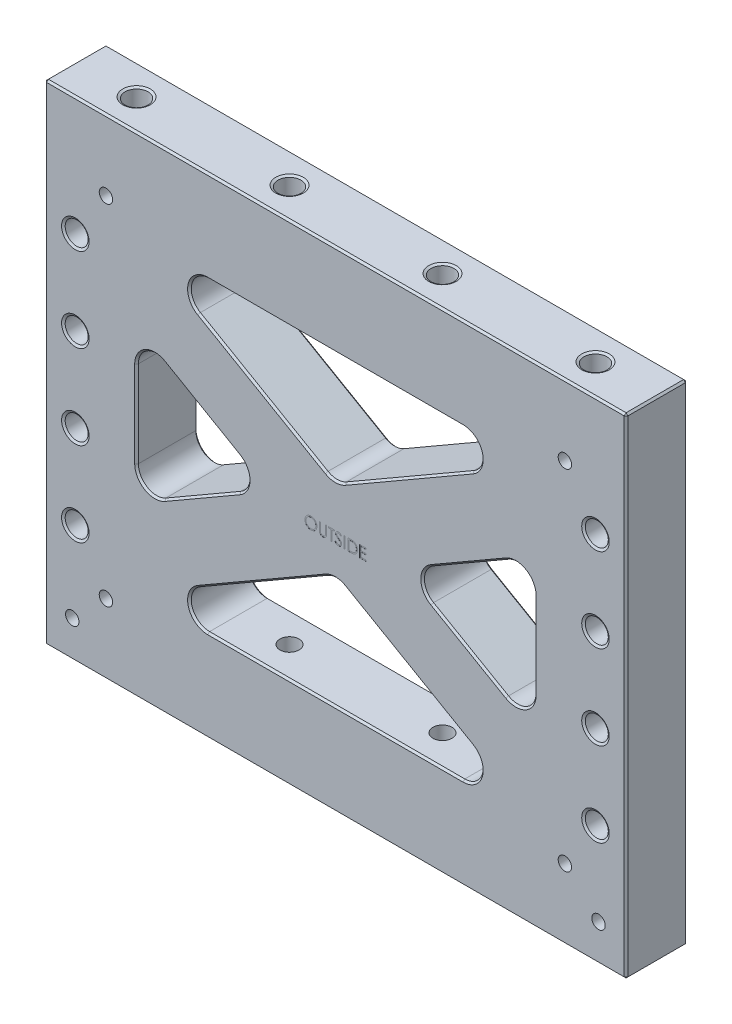
from build123d import *

# Parameters (mm, degrees)
SKETCH1_W                              = 241.3
SKETCH1_H                              = 203.2
EXTRUDE1_DEPTH                         = 25.4
SKETCH2_W                              = 165.1
SKETCH2_H                              = 127
EXTRUDE2_DEPTH                         = 26.4
EXTRUDE3_DEPTH                         = 25.4
FILLET1_R                              = 7.62
CHAMFER1_SIZE                          = 0.762
CHAMFER2_SIZE                          = 0.762
F_3_8_16_TAPPED_HOLE1_AT_2_COUNT       = 2
F_3_8_16_TAPPED_HOLE1_AT_2_PITCH       = 63.5
F_3_8_16_TAPPED_HOLE2_AT_2_COUNT       = 2
F_3_8_16_TAPPED_HOLE2_AT_2_PITCH       = 63.5
F_3_8_16_TAPPED_HOLE3_AT_2_COUNT       = 2
F_3_8_16_TAPPED_HOLE3_AT_2_PITCH       = 190.5
F_3_8_16_TAPPED_HOLE4_AT_2_COUNT       = 2
F_3_8_16_TAPPED_HOLE4_AT_2_PITCH       = 190.5
F_7_32_0_21875_VENT_HOLE1_D            = 5.55625
F_3_8_16_TAPPED_HOLE5_AT_2_COUNT       = 2
F_3_8_16_TAPPED_HOLE5_AT_2_PITCH       = 34.925
F_3_8_16_TAPPED_HOLE5_AT_3_COUNT       = 2
F_3_8_16_TAPPED_HOLE5_AT_3_PITCH       = 69.85
F_3_8_16_TAPPED_HOLE5_AT_4_COUNT       = 2
F_3_8_16_TAPPED_HOLE5_AT_4_PITCH       = 104.775
F_3_8_16_TAPPED_HOLE5_AT_5_COUNT       = 2
F_3_8_16_TAPPED_HOLE5_AT_5_PITCH       = 215.9
F_3_8_16_TAPPED_HOLE5_AT_6_COUNT       = 2
F_3_8_16_TAPPED_HOLE5_AT_6_PITCH       = 218.706574261
F_3_8_16_TAPPED_HOLE5_AT_7_COUNT       = 2
F_3_8_16_TAPPED_HOLE5_AT_7_PITCH       = 226.918118492
F_3_8_16_TAPPED_HOLE5_AT_8_COUNT       = 2
F_3_8_16_TAPPED_HOLE5_AT_8_PITCH       = 239.980438005
F_3_8_0_375_DIAMETER_HOLE2_D           = 9.54278
F_3_8_0_375_DIAMETER_HOLE2_DEPTH       = 19.05
F_3_8_0_375_DIAMETER_HOLE2_CSINK_D     = 14.224
F_3_8_0_375_DIAMETER_HOLE2_CSINK_ANGLE = 90
F_3_8_0_375_DIAMETER_HOLE2_TIP         = 2.866940349
EXTRUDE14_DEPTH                        = 19.05
CHAMFER4_SIZE                          = 2.286
F_7_32_0_21875_DIAMETER_HOLE3_D        = 5.55625
SKETCH36_W                             = 0.427403846
SKETCH36_H                             = 4.7625
EXTRUDE15_DEPTH                        = 0.0254


with BuildPart() as part:
    # Sketch1 → Extrude1 (new body)
    with BuildSketch(Plane.XY):
        with Locations((0, 101.6)):
            Rectangle(SKETCH1_W, SKETCH1_H)
    extrude(amount=EXTRUDE1_DEPTH)

    # Sketch2 → Extrude2 (cut, through all)
    with BuildSketch(Plane.XY.offset(25.4)):
        with Locations((0, 101.6)):
            Rectangle(SKETCH2_W, SKETCH2_H)
    extrude(amount=-EXTRUDE2_DEPTH, mode=Mode.SUBTRACT)

    # Sketch3 → Extrude3 (add)
    with BuildSketch(Plane.XY.offset(25.4)):
        Polygon((-82.55, 132.76248078), (-82.55, 165.1), (-81.410226281, 165.1), (82.55, 70.43751922), (82.55, 38.1), (81.410226281, 38.1), align=None)
    extrude3 = extrude(amount=-EXTRUDE3_DEPTH)

    # Mirror1: Extrude3 across plane
    add(extrude3.mirror(Plane(origin=(0, 0, 0), x_dir=(0, 0, 1), z_dir=(1, 0, 0))))

    # Fillet1
    fillet1_edges = [part.edges().sort_by_distance(p)[0] for p in [
        (82.55, 70.43751922, 12.7),
        (-81.410226281, 165.1, 12.7),
        (-82.55, 132.76248078, 12.7),
        (81.410226281, 38.1, 12.7),
        (-28.575, 101.6, 12.7),
        (0, 85.102216058, 12.7),
        (28.575, 101.6, 12.7),
        (82.55, 132.76248078, 12.7),
        (0, 118.097783942, 12.7),
        (-81.410226281, 38.1, 12.7),
        (-82.55, 70.43751922, 12.7),
        (81.410226281, 165.1, 12.7),
    ]]
    fillet(fillet1_edges, radius=FILLET1_R)

    # Chamfer1
    chamfer1_edges = [part.edges().sort_by_distance(p)[0] for p in [
        (82.55, 101.6, 0),
        (82.55, 101.6, 25.4),
        (55.5625, 86.01875961, 0),
        (55.5625, 86.01875961, 25.4),
        (55.5625, 117.18124039, 0),
        (55.5625, 117.18124039, 25.4),
        (-30.295999563, 135.589187445, 25.4),
        (-30.295999563, 135.589187445, 0),
        (-60.332353923, 43.747798876, 25.4),
        (-60.332353923, 43.747798876, 0),
        (60.332353923, 43.747798876, 25.4),
        (60.332353923, 43.747798876, 0),
        (0, 83.923397955, 0),
        (0, 83.923397955, 25.4),
        (60.332353923, 159.452201124, 25.4),
        (60.332353923, 159.452201124, 0),
        (-78.74, 126.163367203, 25.4),
        (-78.74, 126.163367203, 0),
        (-78.74, 77.036632797, 25.4),
        (-78.74, 77.036632797, 0),
        (-36.195, 101.6, 25.4),
        (-36.195, 101.6, 0),
        (78.74, 77.036632797, 25.4),
        (78.74, 77.036632797, 0),
        (78.74, 126.163367203, 25.4),
        (78.74, 126.163367203, 0),
        (36.195, 101.6, 25.4),
        (36.195, 101.6, 0),
        (0, 119.276602045, 0),
        (0, 119.276602045, 25.4),
        (-60.332353923, 159.452201124, 25.4),
        (-60.332353923, 159.452201124, 0),
        (0, 38.1, 25.4),
        (0, 38.1, 0),
        (-30.295999563, 67.610812555, 25.4),
        (-30.295999563, 67.610812555, 0),
        (30.295999563, 67.610812555, 25.4),
        (30.295999563, 67.610812555, 0),
        (0, 165.1, 25.4),
        (0, 165.1, 0),
        (30.295999563, 135.589187445, 25.4),
        (30.295999563, 135.589187445, 0),
        (-82.55, 101.6, 0),
        (-82.55, 101.6, 25.4),
        (-55.5625, 117.18124039, 0),
        (-55.5625, 117.18124039, 25.4),
        (-55.5625, 86.01875961, 0),
        (-55.5625, 86.01875961, 25.4),
    ]]
    chamfer(chamfer1_edges, length=CHAMFER1_SIZE)

    # Chamfer2
    chamfer2_edges = [part.edges().sort_by_distance(p)[0] for p in [
        (120.65, 101.6, 25.4),
        (0, 203.2, 25.4),
        (-120.65, 101.6, 25.4),
        (0, 203.2, 0),
        (120.65, 101.6, 0),
        (0, 0, 0),
        (-120.65, 101.6, 0),
        (0, 0, 25.4),
        (-120.65, 203.2, 12.7),
        (120.65, 203.2, 12.7),
        (120.65, 0, 12.7),
        (-120.65, 0, 12.7),
    ]]
    chamfer(chamfer2_edges, length=CHAMFER2_SIZE)

    # Sketch6 → 3/8-16 Tapped Hole1 (revolve, cut)
    with BuildSketch(Plane(origin=(-31.75, 203.2, 12.7), x_dir=(0, 0, 1), z_dir=(1, 0, 0))):
        Polygon((0, 0), (0, 40.484665582), (3.96875, 38.1), (3.96875, 25.4), (4.7625, 25.4), (4.7625, 0.549926131), (5.715, 0), align=None)
    f_3_8_16_tapped_hole1 = revolve(axis=Axis((-31.75, 209.55, 12.7), (0, -1, 0)), mode=Mode.SUBTRACT)

    # 3/8-16 Tapped Hole1 at 2: 3/8-16 Tapped Hole1 ×2
    with Locations(*[(i * F_3_8_16_TAPPED_HOLE1_AT_2_PITCH, 0, 0) for i in range(1, F_3_8_16_TAPPED_HOLE1_AT_2_COUNT)]):
        add(f_3_8_16_tapped_hole1, mode=Mode.SUBTRACT)

    # Sketch8 → 3/8-16 Tapped Hole2 (revolve, cut)
    with BuildSketch(Plane(origin=(-31.75, 0, 12.7), x_dir=(0, 0, -1), z_dir=(1, 0, 0))):
        Polygon((0, 0), (0, 40.484665582), (3.96875, 38.1), (3.96875, 25.4), (4.7625, 25.4), (4.7625, 0.549926131), (5.715, 0), align=None)
    f_3_8_16_tapped_hole2 = revolve(axis=Axis((-31.75, -6.35, 12.7), (0, 1, 0)), mode=Mode.SUBTRACT)

    # 3/8-16 Tapped Hole2 at 2: 3/8-16 Tapped Hole2 ×2
    with Locations(*[(i * F_3_8_16_TAPPED_HOLE2_AT_2_PITCH, 0, 0) for i in range(1, F_3_8_16_TAPPED_HOLE2_AT_2_COUNT)]):
        add(f_3_8_16_tapped_hole2, mode=Mode.SUBTRACT)

    # Sketch10 → 3/8-16 Tapped Hole3 (revolve, cut)
    with BuildSketch(Plane(origin=(-95.25, 203.2, 12.7), x_dir=(0, 0, 1), z_dir=(1, 0, 0))):
        Polygon((0, 0), (0, 40.484665582), (3.96875, 38.1), (3.96875, 25.4), (4.7625, 25.4), (4.7625, 0.549926131), (5.715, 0), align=None)
    f_3_8_16_tapped_hole3 = revolve(axis=Axis((-95.25, 209.55, 12.7), (0, -1, 0)), mode=Mode.SUBTRACT)

    # 3/8-16 Tapped Hole3 at 2: 3/8-16 Tapped Hole3 ×2
    with Locations(*[(i * F_3_8_16_TAPPED_HOLE3_AT_2_PITCH, 0, 0) for i in range(1, F_3_8_16_TAPPED_HOLE3_AT_2_COUNT)]):
        add(f_3_8_16_tapped_hole3, mode=Mode.SUBTRACT)

    # Sketch12 → 3/8-16 Tapped Hole4 (revolve, cut)
    with BuildSketch(Plane(origin=(-95.25, 0, 12.7), x_dir=(0, 0, -1), z_dir=(1, 0, 0))):
        Polygon((0, 0), (0, 40.484665582), (3.96875, 38.1), (3.96875, 25.4), (4.7625, 25.4), (4.7625, 0.549926131), (5.715, 0), align=None)
    f_3_8_16_tapped_hole4 = revolve(axis=Axis((-95.25, -6.35, 12.7), (0, 1, 0)), mode=Mode.SUBTRACT)

    # 3/8-16 Tapped Hole4 at 2: 3/8-16 Tapped Hole4 ×2
    with Locations(*[(i * F_3_8_16_TAPPED_HOLE4_AT_2_PITCH, 0, 0) for i in range(1, F_3_8_16_TAPPED_HOLE4_AT_2_COUNT)]):
        add(f_3_8_16_tapped_hole4, mode=Mode.SUBTRACT)

    # 7/32 (0.21875) Vent Hole1 (through all)
    with Locations(Plane.XY.offset(25.4)):
        with Locations((-95.25, 173.99), (95.25, 173.99), (-95.25, 29.21), (95.25, 29.21)):
            Hole(F_7_32_0_21875_VENT_HOLE1_D / 2)

    # Sketch14 → 3/8-16 Tapped Hole5 (revolve, cut)
    with BuildSketch(Plane(origin=(-107.95, 153.9875, 0), x_dir=(0, 1, 0), z_dir=(1, 0, 0))):
        Polygon((0, 0), (0, 25.4), (5.715, 25.4), (4.7625, 24.850073869), (4.7625, 0.549926131), (5.715, 0), align=None)
    f_3_8_16_tapped_hole5 = revolve(axis=Axis((-107.95, 153.9875, -6.35), (0, 0, 1)), mode=Mode.SUBTRACT)

    # 3/8-16 Tapped Hole5 at 2: 3/8-16 Tapped Hole5 ×2
    with Locations(*[(0, -i * F_3_8_16_TAPPED_HOLE5_AT_2_PITCH, 0) for i in range(1, F_3_8_16_TAPPED_HOLE5_AT_2_COUNT)]):
        add(f_3_8_16_tapped_hole5, mode=Mode.SUBTRACT)

    # 3/8-16 Tapped Hole5 at 3: 3/8-16 Tapped Hole5 ×2
    with Locations(*[(0, -i * F_3_8_16_TAPPED_HOLE5_AT_3_PITCH, 0) for i in range(1, F_3_8_16_TAPPED_HOLE5_AT_3_COUNT)]):
        add(f_3_8_16_tapped_hole5, mode=Mode.SUBTRACT)

    # 3/8-16 Tapped Hole5 at 4: 3/8-16 Tapped Hole5 ×2
    with Locations(*[(0, -i * F_3_8_16_TAPPED_HOLE5_AT_4_PITCH, 0) for i in range(1, F_3_8_16_TAPPED_HOLE5_AT_4_COUNT)]):
        add(f_3_8_16_tapped_hole5, mode=Mode.SUBTRACT)

    # 3/8-16 Tapped Hole5 at 5: 3/8-16 Tapped Hole5 ×2
    with Locations(*[(i * F_3_8_16_TAPPED_HOLE5_AT_5_PITCH, 0, 0) for i in range(1, F_3_8_16_TAPPED_HOLE5_AT_5_COUNT)]):
        add(f_3_8_16_tapped_hole5, mode=Mode.SUBTRACT)

    # 3/8-16 Tapped Hole5 at 6: 3/8-16 Tapped Hole5 ×2
    with Locations(*[Vector(0.987167399, -0.159688844, 0) * (i * F_3_8_16_TAPPED_HOLE5_AT_6_PITCH) for i in range(1, F_3_8_16_TAPPED_HOLE5_AT_6_COUNT)]):
        add(f_3_8_16_tapped_hole5, mode=Mode.SUBTRACT)

    # 3/8-16 Tapped Hole5 at 7: 3/8-16 Tapped Hole5 ×2
    with Locations(*[Vector(0.951444519, -0.307820285, 0) * (i * F_3_8_16_TAPPED_HOLE5_AT_7_PITCH) for i in range(1, F_3_8_16_TAPPED_HOLE5_AT_7_COUNT)]):
        add(f_3_8_16_tapped_hole5, mode=Mode.SUBTRACT)

    # 3/8-16 Tapped Hole5 at 8: 3/8-16 Tapped Hole5 ×2
    with Locations(*[Vector(0.899656663, -0.436598086, 0) * (i * F_3_8_16_TAPPED_HOLE5_AT_8_PITCH) for i in range(1, F_3_8_16_TAPPED_HOLE5_AT_8_COUNT)]):
        add(f_3_8_16_tapped_hole5, mode=Mode.SUBTRACT)

    # 3/8 (0.375) Diameter Hole2
    with Locations(Plane.XZ):
        with Locations((-109.22, 12.7)):
            CounterSinkHole(F_3_8_0_375_DIAMETER_HOLE2_D / 2, F_3_8_0_375_DIAMETER_HOLE2_CSINK_D / 2, depth=F_3_8_0_375_DIAMETER_HOLE2_DEPTH, counter_sink_angle=F_3_8_0_375_DIAMETER_HOLE2_CSINK_ANGLE)
            with Locations((0, 0, -(F_3_8_0_375_DIAMETER_HOLE2_DEPTH + F_3_8_0_375_DIAMETER_HOLE2_TIP / 2))):  # 118° drill point
                Cone(0, F_3_8_0_375_DIAMETER_HOLE2_D / 2, F_3_8_0_375_DIAMETER_HOLE2_TIP, mode=Mode.SUBTRACT)

    # Sketch33 → Extrude14 (cut)
    with BuildSketch(Plane.XZ):
        with BuildLine():
            Line((108.458, 17.47139), (109.982, 17.47139))
            ThreePointArc((109.982, 17.47139), (114.75339, 12.7), (109.982, 7.92861))
            Line((109.982, 7.92861), (108.458, 7.92861))
            ThreePointArc((108.458, 7.92861), (103.68661, 12.7), (108.458, 17.47139))
        make_face()
    extrude(amount=-EXTRUDE14_DEPTH, mode=Mode.SUBTRACT)

    # Chamfer4
    chamfer4_edges = [part.edges().sort_by_distance(p)[0] for p in [
        (103.68661, 0, 12.7),
        (109.22, 0, 7.92861),
        (114.75339, 0, 12.7),
        (109.22, 0, 17.47139),
    ]]
    chamfer(chamfer4_edges, length=CHAMFER4_SIZE)

    # 7/32 (0.21875) Diameter Hole3 (through all)
    with Locations(Plane.XY.offset(25.4)):
        with Locations((-109.22, 15.24), (109.22, 15.24)):
            Hole(F_7_32_0_21875_DIAMETER_HOLE3_D / 2)

    # Sketch36 → Extrude15 (cut)
    with BuildSketch(Plane.XY.offset(25.4)):
        with BuildLine():
            add(Edge.make_bspline(
                [(-10.196634615, 101.416581423), (-10.1084493, 101.414347838), (-9.935246064, 101.409960894), (-9.680690579, 101.376379686), (-9.437673681, 101.318283458), (-9.204215742, 101.240909186), (-8.983109228, 101.13769304), (-8.772689878, 101.012935749), (-8.573458346, 100.865330282), (-8.388099966, 100.696017655), (-8.218477473, 100.511799456), (-8.06903582, 100.315206299), (-7.943792556, 100.107426858), (-7.840941896, 99.889085513), (-7.760253431, 99.660676057), (-7.704574303, 99.420980789), (-7.669007749, 99.171552757), (-7.664849709, 99.001426916), (-7.662740385, 98.915124091)],
                knots=[0, 0, 0, 0, 1.065120563, 2.091984664, 3.0946048, 4.079830382, 5.057816894, 6.036188127, 7.030412546, 8.04752943, 9.064399622, 10.05169764, 11.02544977, 11.989514704, 12.962713494, 13.945757189, 14.957906945, 16, 16, 16, 16], degree=3))
            add(Edge.make_bspline(
                [(-7.662740385, 98.915124091), (-7.6648494, 98.829456994), (-7.669006513, 98.660597222), (-7.704614743, 98.412752036), (-7.760459818, 98.174503624), (-7.840192594, 97.946249718), (-7.942552978, 97.727749533), (-8.068630193, 97.519577999), (-8.217140197, 97.321666871), (-8.386150234, 97.13618428), (-8.570392366, 96.966098436), (-8.768009265, 96.817890966), (-8.974556604, 96.690359211), (-9.192692314, 96.588599997), (-9.419523435, 96.507267491), (-9.657080096, 96.451814805), (-9.904249157, 96.41604565), (-10.072802202, 96.411938312), (-10.158473558, 96.409850654)],
                knots=[0, 0, 0, 0, 1.043624062, 2.057103931, 3.04512605, 4.022047818, 4.998200453, 5.980619268, 6.982898556, 8.009068085, 9.034988726, 10.034168286, 11.015286542, 11.987931943, 12.962482838, 13.94673481, 14.956375938, 16, 16, 16, 16], degree=3))
            add(Edge.make_bspline(
                [(-10.158473558, 96.409850654), (-10.244775935, 96.411958926), (-10.414900893, 96.416114893), (-10.664642359, 96.451740305), (-10.904506003, 96.507449722), (-11.133805888, 96.587064348), (-11.352669882, 96.689957794), (-11.56152603, 96.815421609), (-11.759536012, 96.964293469), (-11.945058174, 97.133248701), (-12.114806191, 97.317178563), (-12.262796627, 97.514256603), (-12.388288656, 97.720616349), (-12.490836619, 97.93683048), (-12.572022901, 98.161853765), (-12.627410529, 98.397187229), (-12.663246235, 98.641489199), (-12.667375794, 98.807826858), (-12.669471154, 98.892227456)],
                knots=[0, 0, 0, 0, 1.053102029, 2.075944431, 3.073151272, 4.055350789, 5.033113405, 6.020478099, 7.024410459, 8.052272461, 9.079885166, 10.07527673, 11.055994387, 12.023226415, 12.992069828, 13.970394897, 14.97016774, 16, 16, 16, 16], degree=3))
            add(Edge.make_bspline(
                [(-12.669471154, 98.892227456), (-12.668743668, 98.948877624), (-12.667297873, 99.061463292), (-12.649892034, 99.22864963), (-12.624634862, 99.393147275), (-12.58843726, 99.554488458), (-12.541095741, 99.712278227), (-12.485235661, 99.8676048), (-12.417009658, 100.018894081), (-12.33988349, 100.166862768), (-12.253802244, 100.30920424), (-12.158721314, 100.443751101), (-12.05798033, 100.571632386), (-11.947540141, 100.689534202), (-11.831040621, 100.800886427), (-11.706591899, 100.903977839), (-11.574953345, 100.99973804), (-11.435558536, 101.086035004), (-11.29184224, 101.164084398), (-11.143692053, 101.231061274), (-10.993120076, 101.288546093), (-10.839421072, 101.335138073), (-10.683003193, 101.371920951), (-10.523525051, 101.3969681), (-10.361113696, 101.414418332), (-10.251696865, 101.41585729), (-10.196634615, 101.416581423)],
                knots=[0, 0, 0, 0, 1.037015668, 2.060948919, 3.074880161, 4.083647147, 5.086022904, 6.090072063, 7.104153813, 8.122640571, 9.144368836, 10.147691507, 11.138137339, 12.123020368, 13.103399296, 14.087645067, 15.080126199, 16.082011238, 17.087798457, 18.072939717, 19.057185487, 20.037253025, 21.01195951, 21.997135196, 22.992090687, 24, 24, 24, 24], degree=3))
        make_face()
        with BuildLine():
            add(Edge.make_bspline(
                [(-10.175646034, 100.928119884), (-10.22084166, 100.927568944), (-10.310800839, 100.926472332), (-10.444538012, 100.912027376), (-10.576516322, 100.89143992), (-10.706763025, 100.862073636), (-10.834733155, 100.822063121), (-10.961619546, 100.776015314), (-11.08626513, 100.719925187), (-11.208258415, 100.656553043), (-11.326525, 100.58640969), (-11.438120854, 100.508887393), (-11.54333488, 100.425804146), (-11.641909468, 100.336966053), (-11.73355517, 100.241920702), (-11.820075782, 100.142108994), (-11.89800332, 100.034678028), (-11.969421194, 99.92254101), (-12.033331005, 99.805844002), (-12.09016172, 99.685815582), (-12.136649175, 99.561476658), (-12.174561908, 99.434176179), (-12.205994151, 99.304115761), (-12.22590674, 99.170308767), (-12.240510415, 99.033427561), (-12.241544348, 98.940923681), (-12.242067308, 98.894135509)],
                knots=[0, 0, 0, 0, 1.008559885, 2.007477868, 2.99961109, 3.989939068, 4.984837346, 5.991145699, 7.001802488, 8.033829008, 9.059044045, 10.069351652, 11.065060232, 12.050310815, 13.029377138, 14.011219647, 14.996725999, 15.989392538, 16.977580475, 17.965360261, 18.951710183, 19.937753436, 20.929683414, 21.935841486, 22.955955122, 24, 24, 24, 24], degree=3))
            add(Edge.make_bspline(
                [(-12.242067308, 98.894135509), (-12.240332585, 98.825334773), (-12.236919848, 98.689982441), (-12.207041869, 98.491633645), (-12.161019825, 98.301013513), (-12.093178194, 98.119165058), (-12.008336822, 97.944525158), (-11.903525232, 97.778643059), (-11.779347691, 97.621473926), (-11.638291249, 97.474115007), (-11.484091424, 97.339614109), (-11.320352959, 97.221553899), (-11.148830014, 97.121663523), (-10.969075299, 97.040285907), (-10.782048469, 96.975802014), (-10.586544373, 96.931607877), (-10.383865355, 96.902521989), (-10.245711142, 96.899728775), (-10.175646034, 96.898312192)],
                knots=[0, 0, 0, 0, 1.032063989, 2.030389145, 3.003944642, 3.970395727, 4.937377036, 5.913328081, 6.909231446, 7.93887556, 8.970685674, 9.976071282, 10.964166581, 11.944589148, 12.933237628, 13.927779006, 14.949070134, 16, 16, 16, 16], degree=3))
            add(Edge.make_bspline(
                [(-10.175646034, 96.898312192), (-10.12855239, 96.898959218), (-10.035151552, 96.900242464), (-9.896228716, 96.913167449), (-9.759808656, 96.933893671), (-9.626082718, 96.963735028), (-9.495202671, 97.001082834), (-9.366622243, 97.045452635), (-9.241710998, 97.10080813), (-9.118893147, 97.16196945), (-9.001332547, 97.231692664), (-8.889106912, 97.306583861), (-8.785044953, 97.389544734), (-8.68654411, 97.4770629), (-8.594522147, 97.570902993), (-8.509601351, 97.670943009), (-8.432067671, 97.777814404), (-8.360676916, 97.889781331), (-8.296991048, 98.00679766), (-8.241502345, 98.127261258), (-8.194426916, 98.250875496), (-8.156424201, 98.37781867), (-8.126644341, 98.507849682), (-8.106124878, 98.641142638), (-8.091771467, 98.777430886), (-8.090689594, 98.869610919), (-8.090144231, 98.916078118)],
                knots=[0, 0, 0, 0, 1.047197238, 2.076906641, 3.100256066, 4.114471768, 5.12198147, 6.126382909, 7.136867548, 8.15857795, 9.17633901, 10.174870724, 11.156907918, 12.133735059, 13.104061851, 14.077631395, 15.04955518, 16.038496417, 17.029181396, 18.010275684, 18.986308667, 19.968651475, 20.955262928, 21.950658345, 22.966943676, 24, 24, 24, 24], degree=3))
            add(Edge.make_bspline(
                [(-8.090144231, 98.916078118), (-8.090690031, 98.962227429), (-8.091772726, 99.053773088), (-8.106118022, 99.189110845), (-8.126666019, 99.321444679), (-8.156278847, 99.450255068), (-8.194447092, 99.575574847), (-8.241510566, 99.697286314), (-8.297007706, 99.815842894), (-8.360700326, 99.930951562), (-8.432295428, 100.041407188), (-8.510528666, 100.147001899), (-8.596750801, 100.245752665), (-8.688498356, 100.340097374), (-8.788063025, 100.428023859), (-8.894993797, 100.509561289), (-9.007992515, 100.586677423), (-9.127636361, 100.656244706), (-9.251112955, 100.720489787), (-9.377814448, 100.775532044), (-9.506305473, 100.822302678), (-9.636259283, 100.862194691), (-9.768769692, 100.891324904), (-9.902941331, 100.912045929), (-10.038588569, 100.926467304), (-10.129815235, 100.927567276), (-10.175646034, 100.928119884)],
                knots=[0, 0, 0, 0, 1.02996197, 2.043119294, 3.035359645, 4.018872909, 4.991431989, 5.957985074, 6.929999688, 7.912076566, 8.892894881, 9.867085534, 10.843653904, 11.817741046, 12.803660682, 13.806313499, 14.818574707, 15.856120519, 16.894564902, 17.924820532, 18.937903209, 19.946497019, 20.957711757, 21.963978472, 22.977135795, 24, 24, 24, 24], degree=3))
        make_face(mode=Mode.SUBTRACT)
        with BuildLine():
            Line((-6.685817308, 101.294466038), (-6.258413462, 101.294466038))
            Line((-6.258413462, 101.294466038), (-6.258413462, 98.440972949))
            add(Edge.make_bspline(
                [(-6.258413462, 98.440972949), (-6.258477067, 98.400585948), (-6.258597769, 98.323944654), (-6.257791526, 98.214858502), (-6.2555336, 98.117877049), (-6.254110076, 98.032626465), (-6.25094324, 97.959497941), (-6.24836054, 97.898095286), (-6.24503964, 97.848709246), (-6.241048505, 97.819888057), (-6.239332933, 97.807499392)],
                knots=[0, 0, 0, 0, 1.528628734, 2.90083645, 4.128790002, 5.200304208, 6.127813768, 6.898992206, 7.526736466, 8, 8, 8, 8], degree=3))
            add(Edge.make_bspline(
                [(-6.239332933, 97.807499392), (-6.232287891, 97.762804331), (-6.218594769, 97.675932618), (-6.183697377, 97.55223242), (-6.134959991, 97.440747114), (-6.077207137, 97.337997822), (-6.001098833, 97.246844443), (-5.909926166, 97.162872515), (-5.799466416, 97.089432309), (-5.676647521, 97.022279955), (-5.544270108, 96.968307111), (-5.408999778, 96.927494711), (-5.272869867, 96.902622351), (-5.181734442, 96.899742346), (-5.136478365, 96.898312192)],
                knots=[0, 0, 0, 0, 1.035780045, 2.013197591, 2.933192213, 3.817615948, 4.702609284, 5.640816605, 6.646850145, 7.73207398, 8.84249596, 9.914020372, 10.964143139, 12, 12, 12, 12], degree=3))
            add(Edge.make_bspline(
                [(-5.136478365, 96.898312192), (-5.097624883, 96.899773395), (-5.020142325, 96.902687363), (-4.905017147, 96.920732381), (-4.792894142, 96.953254223), (-4.683219645, 96.995218322), (-4.580416341, 97.050664152), (-4.484426872, 97.114714115), (-4.398750947, 97.189840343), (-4.320567029, 97.272980455), (-4.252483777, 97.366787826), (-4.193468045, 97.469219863), (-4.145127405, 97.581818082), (-4.12125568, 97.660949635), (-4.108991887, 97.701602456)],
                knots=[0, 0, 0, 0, 0.994687771, 1.983630487, 2.973142513, 3.978332533, 4.983357753, 5.956394766, 6.925816176, 7.893390482, 8.871859704, 9.88551698, 10.913711441, 12, 12, 12, 12], degree=3))
            add(Edge.make_bspline(
                [(-4.108991887, 97.701602456), (-4.104909574, 97.718405338), (-4.095812534, 97.75584893), (-4.087312091, 97.819151114), (-4.078458569, 97.893839856), (-4.072315529, 97.980451787), (-4.066326726, 98.078696682), (-4.062743866, 98.189086339), (-4.061087832, 98.311219918), (-4.060594327, 98.396451199), (-4.060336538, 98.440972949)],
                knots=[0, 0, 0, 0, 0.558680831, 1.244966039, 2.062412453, 2.990489873, 4.051219941, 5.244515665, 6.560634259, 8, 8, 8, 8], degree=3))
            Line((-4.060336538, 98.440972949), (-4.060336538, 101.294466038))
            Line((-4.060336538, 101.294466038), (-3.632932692, 101.294466038))
            Line((-3.632932692, 101.294466038), (-3.632932692, 98.418076315))
            add(Edge.make_bspline(
                [(-3.632932692, 98.418076315), (-3.633278478, 98.366235306), (-3.633953298, 98.265064426), (-3.639805154, 98.116812755), (-3.649135572, 97.976178877), (-3.662318292, 97.843143887), (-3.679785785, 97.718183835), (-3.699210282, 97.600203418), (-3.723947432, 97.490049525), (-3.752840024, 97.386863271), (-3.785869388, 97.288639411), (-3.828651808, 97.195418761), (-3.876854431, 97.104367381), (-3.934024369, 97.016862419), (-3.998265572, 96.93251643), (-4.070998038, 96.851840939), (-4.149816271, 96.773546737), (-4.236030529, 96.699642172), (-4.328219636, 96.631866794), (-4.426109364, 96.572270541), (-4.528947755, 96.521891976), (-4.636467487, 96.48042295), (-4.748714445, 96.449242727), (-4.86569146, 96.426008319), (-4.987664791, 96.412806264), (-5.070620269, 96.410844209), (-5.112627704, 96.409850654)],
                knots=[0, 0, 0, 0, 1.316592851, 2.569410997, 3.76748051, 4.895814652, 5.963796859, 6.97159953, 7.931736103, 8.829262218, 9.692595152, 10.560224239, 11.431080259, 12.30701507, 13.211635791, 14.121146779, 15.063487852, 16.031507147, 17.00238618, 17.966455255, 18.938106653, 19.907068911, 20.888905087, 21.893141452, 22.933117798, 24, 24, 24, 24], degree=3))
            add(Edge.make_bspline(
                [(-5.112627704, 96.409850654), (-5.158441733, 96.410918495), (-5.248328694, 96.413013596), (-5.380777993, 96.425018838), (-5.507751953, 96.447631724), (-5.630591628, 96.476424362), (-5.747624619, 96.51613509), (-5.860418913, 96.562532896), (-5.96704269, 96.619515882), (-6.069225704, 96.682916178), (-6.164237247, 96.754251132), (-6.251455499, 96.832002583), (-6.331024452, 96.914925025), (-6.401602928, 97.003916237), (-6.464360274, 97.098284095), (-6.518421743, 97.198295561), (-6.564840122, 97.303911913), (-6.588797629, 97.377326803), (-6.600908954, 97.414440497)],
                knots=[0, 0, 0, 0, 1.13879206, 2.234305948, 3.301075583, 4.341971843, 5.366689343, 6.369221514, 7.369726634, 8.367512178, 9.355451585, 10.318319045, 11.268648973, 12.207971039, 13.137398894, 14.081662264, 15.030215811, 16, 16, 16, 16], degree=3))
            add(Edge.make_bspline(
                [(-6.600908954, 97.414440497), (-6.607953587, 97.439794108), (-6.623233553, 97.494786653), (-6.639596548, 97.585800053), (-6.65335212, 97.690595352), (-6.666286468, 97.809179722), (-6.673918658, 97.941645076), (-6.680609887, 98.087933994), (-6.685864447, 98.248223363), (-6.68583346, 98.359876115), (-6.685817308, 98.418076315)],
                knots=[0, 0, 0, 0, 0.625038921, 1.35572334, 2.194682327, 3.136881307, 4.189498639, 5.346923369, 6.617055217, 8, 8, 8, 8], degree=3))
            Line((-6.685817308, 98.418076315), (-6.685817308, 101.294466038))
        make_face()
        Polygon((-2.961298077, 100.8060045), (-2.961298077, 101.294466038), (-0.457932692, 101.294466038), (-0.457932692, 100.8060045), (-1.495913462, 100.8060045), (-1.495913462, 96.531966038), (-1.923317308, 96.531966038), (-1.923317308, 100.8060045), align=None)
        with BuildLine():
            Line((-0.213701923, 97.450693502), (0.188897236, 97.692062192))
            add(Edge.make_bspline(
                [(0.188897236, 97.692062192), (0.226341694, 97.629381725), (0.298083832, 97.50928837), (0.417760503, 97.347012251), (0.541766357, 97.209087316), (0.6710197, 97.096315932), (0.804731579, 97.00753084), (0.943774881, 96.944662803), (1.087681045, 96.905452494), (1.185616852, 96.900689876), (1.234510216, 96.898312192)],
                knots=[0, 0, 0, 0, 1.272034388, 2.437168799, 3.508375237, 4.49857839, 5.41946034, 6.295179144, 7.148887113, 8, 8, 8, 8], degree=3))
            add(Edge.make_bspline(
                [(1.234510216, 96.898312192), (1.276266266, 96.899475157), (1.359047732, 96.901780738), (1.480916355, 96.923934258), (1.599273736, 96.957968619), (1.71168049, 97.006710672), (1.816585594, 97.065681969), (1.90857899, 97.136910161), (1.988107451, 97.216656462), (2.053161996, 97.305623574), (2.103073044, 97.401305123), (2.141434395, 97.499515971), (2.16272287, 97.601798916), (2.165929738, 97.670665295), (2.167548077, 97.705418562)],
                knots=[0, 0, 0, 0, 1.095163259, 2.171163733, 3.241058638, 4.321873601, 5.38011039, 6.391990106, 7.366004449, 8.327778327, 9.272591725, 10.192022065, 11.087607919, 12, 12, 12, 12], degree=3))
            add(Edge.make_bspline(
                [(2.167548077, 97.705418562), (2.165541961, 97.745070933), (2.161463821, 97.825678408), (2.126994915, 97.944604364), (2.072771475, 98.06229604), (2.022748021, 98.135095976), (1.996777344, 98.172891519)],
                knots=[0, 0, 0, 0, 0.938893495, 1.908633276, 2.914225137, 4, 4, 4, 4], degree=3))
            add(Edge.make_bspline(
                [(1.996777344, 98.172891519), (1.975454115, 98.200169518), (1.930688664, 98.257436266), (1.853730049, 98.342678532), (1.763424729, 98.430605738), (1.662863106, 98.524575384), (1.54838201, 98.620216993), (1.423567071, 98.722091328), (1.285231606, 98.826324188), (1.188213362, 98.896227572), (1.138153546, 98.932296567)],
                knots=[0, 0, 0, 0, 0.722233717, 1.516239348, 2.393582979, 3.351407094, 4.387010283, 5.505090956, 6.712668013, 8, 8, 8, 8], degree=3))
            add(Edge.make_bspline(
                [(1.138153546, 98.932296567), (1.088046608, 98.967986181), (0.992245959, 99.036222005), (0.858271959, 99.137492191), (0.738468601, 99.230080457), (0.633368367, 99.314858416), (0.543017487, 99.391837567), (0.466703989, 99.460278692), (0.406371881, 99.522032751), (0.37282268, 99.562094006), (0.357759916, 99.580080521)],
                knots=[0, 0, 0, 0, 1.452282411, 2.77665338, 3.964542531, 5.026858415, 5.96415736, 6.766646006, 7.446254459, 8, 8, 8, 8], degree=3))
            add(Edge.make_bspline(
                [(0.357759916, 99.580080521), (0.336706203, 99.608112647), (0.29530125, 99.663241583), (0.240646792, 99.749408621), (0.194193146, 99.837614565), (0.157777258, 99.928096437), (0.127111903, 100.019583966), (0.10648629, 100.113270839), (0.093571211, 100.208736674), (0.092248615, 100.272980759), (0.091586538, 100.305140618)],
                knots=[0, 0, 0, 0, 1.068054152, 2.10047183, 3.106115577, 4.101338837, 5.06977816, 6.043150881, 7.020423561, 8, 8, 8, 8], degree=3))
            add(Edge.make_bspline(
                [(0.091586538, 100.305140618), (0.093362555, 100.355527561), (0.096876627, 100.455224462), (0.126595331, 100.600862842), (0.17350309, 100.73990936), (0.239218633, 100.870987421), (0.323933103, 100.990683988), (0.42196709, 101.100375911), (0.538732005, 101.192589589), (0.666846824, 101.273160283), (0.807077102, 101.336223845), (0.954021867, 101.38379575), (1.107914669, 101.41075049), (1.212149648, 101.414618681), (1.265039063, 101.416581423)],
                knots=[0, 0, 0, 0, 1.005424448, 1.989358655, 2.955360095, 3.929531133, 4.905563448, 5.876582895, 6.856512386, 7.866279853, 8.892233794, 9.918561126, 10.94386622, 12, 12, 12, 12], degree=3))
            add(Edge.make_bspline(
                [(1.265039063, 101.416581423), (1.321160499, 101.414645737), (1.432768124, 101.410796274), (1.596937235, 101.377326062), (1.754998781, 101.321944077), (1.882148367, 101.25909451), (1.98166116, 101.196322833), (2.057551914, 101.139145858), (2.134456017, 101.073321157), (2.212993799, 100.998673397), (2.291834482, 100.914517639), (2.372148536, 100.821430238), (2.454123774, 100.719980067), (2.506859426, 100.647556728), (2.533894231, 100.610429079)],
                knots=[0, 0, 0, 0, 1.286793592, 2.559021753, 3.825965368, 5.121522368, 5.803751409, 6.523245864, 7.299691795, 8.125521123, 9.008227632, 9.944561021, 10.946284179, 12, 12, 12, 12], degree=3))
            Line((2.533894231, 100.610429079), (2.147513522, 100.317542961))
            add(Edge.make_bspline(
                [(2.147513522, 100.317542961), (2.124182806, 100.347599358), (2.079253304, 100.40548095), (2.011041395, 100.48654049), (1.946749485, 100.560585772), (1.883407691, 100.624900107), (1.824361356, 100.683005509), (1.767052095, 100.732752893), (1.712304639, 100.774629685), (1.643293414, 100.819320386), (1.556591804, 100.863620486), (1.447755703, 100.90110691), (1.334018665, 100.923633619), (1.256553702, 100.92661207), (1.21733774, 100.928119884)],
                knots=[0, 0, 0, 0, 1.181633172, 2.275549214, 3.290209073, 4.226197932, 5.078386478, 5.862611352, 6.581680152, 7.217281963, 8.414376989, 9.595101626, 10.782541182, 12, 12, 12, 12], degree=3))
            add(Edge.make_bspline(
                [(1.21733774, 100.928119884), (1.168139044, 100.926471107), (1.073263992, 100.923291595), (0.938566564, 100.888566186), (0.817335187, 100.833890155), (0.713169018, 100.75726156), (0.626441203, 100.666473352), (0.563704847, 100.561999267), (0.525944801, 100.446634641), (0.521337042, 100.366159744), (0.518990385, 100.325175173)],
                knots=[0, 0, 0, 0, 1.14458467, 2.207223713, 3.21896685, 4.227309161, 5.202851033, 6.127160689, 7.046193047, 8, 8, 8, 8], degree=3))
            add(Edge.make_bspline(
                [(0.518990385, 100.325175173), (0.519525318, 100.299659768), (0.520596058, 100.248587236), (0.535529622, 100.173133694), (0.554714781, 100.097870764), (0.585116719, 100.023136821), (0.627088364, 99.947624854), (0.682204336, 99.870034561), (0.751618878, 99.789682058), (0.804791527, 99.737420595), (0.832865084, 99.709828118)],
                knots=[0, 0, 0, 0, 0.858281714, 1.717966888, 2.583508476, 3.4729293, 4.427298488, 5.488583878, 6.674047936, 8, 8, 8, 8], degree=3))
            add(Edge.make_bspline(
                [(0.832865084, 99.709828118), (0.843290023, 99.700524879), (0.868057292, 99.678422513), (0.913336319, 99.642238017), (0.973129912, 99.597602816), (1.045876693, 99.542375075), (1.132917996, 99.478310657), (1.234263392, 99.406228706), (1.348783192, 99.323789206), (1.430047656, 99.266152696), (1.473016827, 99.235676976)],
                knots=[0, 0, 0, 0, 0.420754252, 0.999615792, 1.744751191, 2.668019286, 3.750313428, 4.999500688, 6.413464383, 8, 8, 8, 8], degree=3))
            add(Edge.make_bspline(
                [(1.473016827, 99.235676976), (1.524704802, 99.198064983), (1.624791401, 99.125234572), (1.767200465, 99.015811807), (1.896323826, 98.908794665), (2.012614828, 98.804866564), (2.117222335, 98.704815837), (2.208985805, 98.607438795), (2.288840249, 98.51343307), (2.374809114, 98.392911101), (2.462653861, 98.244891125), (2.538093912, 98.063537522), (2.585662235, 97.881478957), (2.591882762, 97.759114226), (2.594951923, 97.698740377)],
                knots=[0, 0, 0, 0, 1.163667725, 2.253281268, 3.268753668, 4.215851969, 5.092017293, 5.902905408, 6.650798638, 7.335211899, 8.59617414, 9.77448103, 10.901945474, 12, 12, 12, 12], degree=3))
            add(Edge.make_bspline(
                [(2.594951923, 97.698740377), (2.594057746, 97.656043388), (2.592286756, 97.571478555), (2.571929227, 97.447306468), (2.542102825, 97.326705178), (2.497148589, 97.211165414), (2.442280291, 97.098573433), (2.372657647, 96.991882683), (2.291956833, 96.888731834), (2.199382317, 96.79187144), (2.098082714, 96.702953938), (1.991016687, 96.623856893), (1.878008994, 96.557905353), (1.759672685, 96.504087957), (1.635980577, 96.461996278), (1.506974271, 96.431498767), (1.372441114, 96.412781175), (1.281000459, 96.410838399), (1.234510216, 96.409850654)],
                knots=[0, 0, 0, 0, 0.983748083, 1.948392443, 2.894712957, 3.844097841, 4.80183111, 5.778335162, 6.776009319, 7.81870978, 8.863265674, 9.881300176, 10.883814829, 11.87499822, 12.874611388, 13.892143829, 14.928324115, 16, 16, 16, 16], degree=3))
            add(Edge.make_bspline(
                [(1.234510216, 96.409850654), (1.198539268, 96.410546226), (1.127050387, 96.41192861), (1.021309985, 96.424149566), (0.917705758, 96.441440304), (0.817537753, 96.468891449), (0.719515418, 96.502197621), (0.624065074, 96.543207281), (0.531140461, 96.592352473), (0.440220821, 96.648543203), (0.351537391, 96.713936063), (0.265921972, 96.790099999), (0.180565473, 96.874934418), (0.097987266, 96.970743078), (0.016517023, 97.075978112), (-0.062238955, 97.191624108), (-0.139910864, 97.31705115), (-0.188645483, 97.405313999), (-0.213701923, 97.450693502)],
                knots=[0, 0, 0, 0, 0.915332311, 1.819136955, 2.706846663, 3.586547465, 4.459518054, 5.340707479, 6.227863349, 7.133153174, 8.059268498, 9.028702269, 10.047606654, 11.120612155, 12.245963614, 13.433783089, 14.680604001, 16, 16, 16, 16], degree=3))
        make_face()
        with Locations((3.785576923, 98.913216038)):
            Rectangle(SKETCH36_W, SKETCH36_H)
        with BuildLine():
            Line((5.220432692, 96.531966038), (5.220432692, 101.294466038))
            Line((5.220432692, 101.294466038), (6.182091346, 101.294466038))
            add(Edge.make_bspline(
                [(6.182091346, 101.294466038), (6.265733077, 101.293863827), (6.427328464, 101.292700358), (6.660843973, 101.285323393), (6.876903307, 101.27227351), (7.074795876, 101.253264976), (7.255064954, 101.229924598), (7.417205774, 101.200668691), (7.562056726, 101.166122644), (7.651141929, 101.136669371), (7.693269231, 101.122741279)],
                knots=[0, 0, 0, 0, 1.314313732, 2.53924729, 3.670748893, 4.714932338, 5.66265055, 6.526160246, 7.303039223, 8, 8, 8, 8], degree=3))
            add(Edge.make_bspline(
                [(7.693269231, 101.122741279), (7.748371001, 101.101744497), (7.857325016, 101.060227071), (8.012456137, 100.98190939), (8.158495291, 100.893172991), (8.296225628, 100.793900906), (8.422501038, 100.681282275), (8.54225464, 100.560101026), (8.650587532, 100.425950463), (8.749794892, 100.281612711), (8.839242343, 100.128788098), (8.916992411, 99.967767825), (8.981563738, 99.799369624), (9.035166664, 99.624061797), (9.077412023, 99.441458869), (9.10623458, 99.251348215), (9.125245105, 99.054481176), (9.127155618, 98.92089378), (9.128125, 98.853112372)],
                knots=[0, 0, 0, 0, 0.984719456, 1.947108742, 2.898477687, 3.838006223, 4.779231079, 5.722358779, 6.681677486, 7.655904652, 8.64651281, 9.637519902, 10.640069247, 11.656948941, 12.698408672, 13.768548281, 14.867775369, 16, 16, 16, 16], degree=3))
            add(Edge.make_bspline(
                [(9.128125, 98.853112372), (9.127269155, 98.794246187), (9.125582623, 98.678244221), (9.110438804, 98.507282859), (9.088427454, 98.341393321), (9.054349456, 98.181365565), (9.012980322, 98.025797526), (8.959961245, 97.876347222), (8.899225087, 97.731643681), (8.828400074, 97.593643473), (8.750646975, 97.462901455), (8.667205603, 97.33965404), (8.578164957, 97.225659899), (8.482675971, 97.120573824), (8.381972614, 97.024554233), (8.275395578, 96.936799026), (8.162669855, 96.859025286), (8.044300336, 96.788176828), (7.916833889, 96.726372701), (7.777856157, 96.674080438), (7.626774447, 96.630746293), (7.463959598, 96.594590896), (7.289130295, 96.565910709), (7.10211513, 96.546688725), (6.90320144, 96.533689913), (6.76661394, 96.532551821), (6.696311599, 96.531966038)],
                knots=[0, 0, 0, 0, 1.105936401, 2.179363191, 3.223086493, 4.248585256, 5.251745608, 6.245858792, 7.225916811, 8.198733463, 9.158002045, 10.082870192, 10.993790845, 11.873723703, 12.748670949, 13.606408763, 14.465103618, 15.319838547, 16.196477973, 17.123216899, 18.106603292, 19.147568657, 20.255746949, 21.433717677, 22.679120308, 24, 24, 24, 24], degree=3))
            Line((6.696311599, 96.531966038), (5.220432692, 96.531966038))
        make_face()
        with BuildLine():
            Line((5.647836538, 97.020427577), (6.19449369, 97.020427577))
            add(Edge.make_bspline(
                [(6.19449369, 97.020427577), (6.273045509, 97.020765165), (6.424129424, 97.021414471), (6.641378341, 97.027112058), (6.83987852, 97.03642198), (7.019658145, 97.049450925), (7.180615711, 97.066689291), (7.323087599, 97.085909248), (7.44660679, 97.109854351), (7.521350059, 97.131559049), (7.555889423, 97.141588935)],
                knots=[0, 0, 0, 0, 1.375205317, 2.645023457, 3.804390687, 4.853969522, 5.800190428, 6.637939096, 7.370582563, 8, 8, 8, 8], degree=3))
            add(Edge.make_bspline(
                [(7.555889423, 97.141588935), (7.599362016, 97.156899091), (7.685268859, 97.18715372), (7.80893205, 97.242341109), (7.924262117, 97.30771264), (8.033268973, 97.380377877), (8.134406315, 97.462899758), (8.228872702, 97.553483854), (8.316477939, 97.652591173), (8.396316908, 97.760098707), (8.467765707, 97.875337322), (8.529639058, 97.997174092), (8.583865607, 98.124274073), (8.626426835, 98.258589035), (8.65978554, 98.398918218), (8.683413919, 98.545271494), (8.698129669, 98.697621531), (8.699846139, 98.801242814), (8.700721154, 98.854066399)],
                knots=[0, 0, 0, 0, 0.998632004, 1.973411704, 2.929992603, 3.868527914, 4.809262121, 5.754881198, 6.702106254, 7.672490631, 8.653608572, 9.636854334, 10.631411391, 11.644891563, 12.686317036, 13.754757253, 14.855430412, 16, 16, 16, 16], degree=3))
            add(Edge.make_bspline(
                [(8.700721154, 98.854066399), (8.700022716, 98.90976517), (8.69865063, 99.0191859), (8.681404515, 99.179737524), (8.656201969, 99.334152267), (8.619757025, 99.482440454), (8.573314651, 99.62489139), (8.515355513, 99.760717224), (8.449134149, 99.89135242), (8.370344252, 100.013781825), (8.284053748, 100.129569234), (8.188289562, 100.235643602), (8.084573145, 100.33224656), (7.974035725, 100.420882554), (7.853562029, 100.497985627), (7.725990043, 100.566955718), (7.589448255, 100.625488056), (7.494453122, 100.656619651), (7.446176382, 100.672440798)],
                knots=[0, 0, 0, 0, 1.122418816, 2.205001699, 3.251619955, 4.274784885, 5.280384055, 6.268708349, 7.249350384, 8.229342522, 9.199999885, 10.157847722, 11.105861043, 12.055065948, 13.010012805, 13.98527497, 14.976112212, 16, 16, 16, 16], degree=3))
            add(Edge.make_bspline(
                [(7.446176382, 100.672440798), (7.406237858, 100.683484937), (7.321317598, 100.706967808), (7.182743184, 100.732583761), (7.026784713, 100.75517774), (6.852749763, 100.774306715), (6.660836716, 100.788032677), (6.450897977, 100.798335073), (6.2228428, 100.805283741), (6.064751567, 100.805758232), (5.98269982, 100.8060045)],
                knots=[0, 0, 0, 0, 0.674548936, 1.434276114, 2.292660221, 3.240891867, 4.284742987, 5.42552168, 6.663806718, 8, 8, 8, 8], degree=3))
            Line((5.98269982, 100.8060045), (5.647836538, 100.8060045))
            Line((5.647836538, 100.8060045), (5.647836538, 97.020427577))
        make_face(mode=Mode.SUBTRACT)
        Polygon((10.105048077, 101.294466038), (12.791586538, 101.294466038), (12.791586538, 100.8060045), (10.532451923, 100.8060045), (10.532451923, 99.340619884), (12.791586538, 99.340619884), (12.791586538, 98.852158346), (10.532451923, 98.852158346), (10.532451923, 97.020427577), (12.791586538, 97.020427577), (12.791586538, 96.531966038), (10.105048077, 96.531966038), align=None)
    extrude(amount=-EXTRUDE15_DEPTH, mode=Mode.SUBTRACT)


solid = part.part
